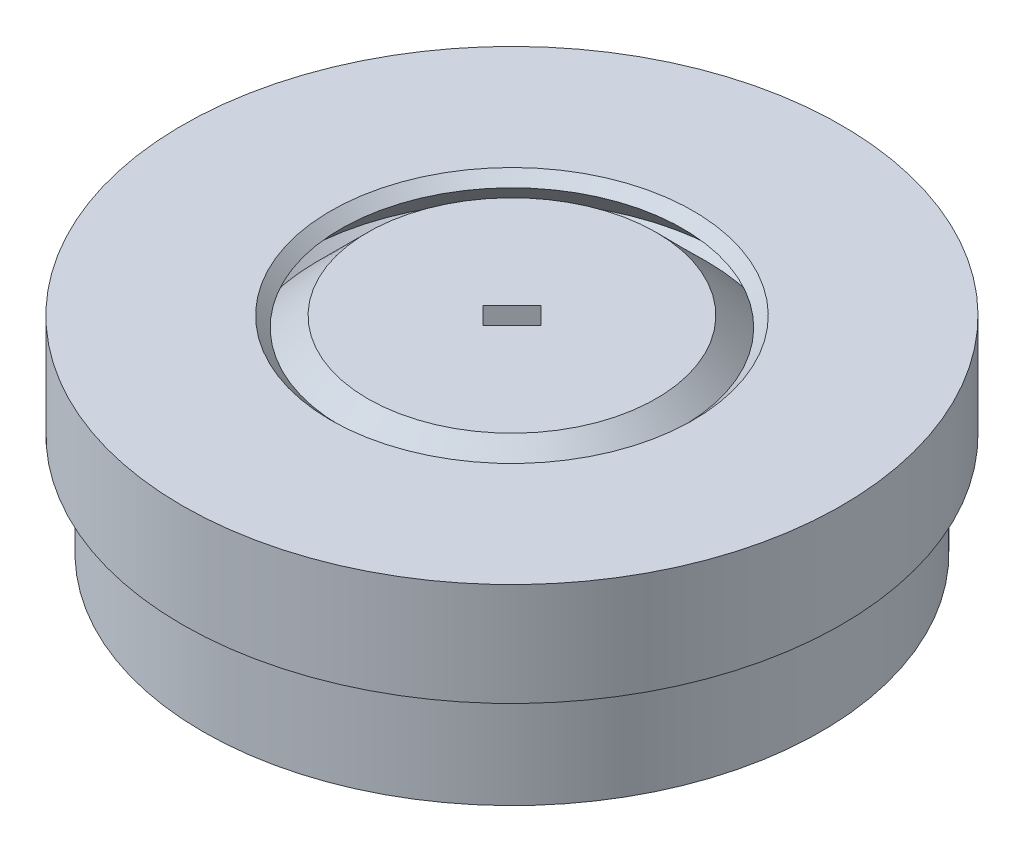
from build123d import *

# Parameters (mm, degrees)
SKETCH3_R             = 15
BOSS_EXTRUDE1_DEPTH   = 3
SKETCH3_W             = 6
SKETCH3_H             = 6
BOSS_EXTRUDE1_2_DEPTH = 3
FILLET2_R             = 0.5
FILLET3_R             = 0.5
CHAMFER1_SIZE         = 0.5
CHAMFER2_SIZE2        = 1
CHAMFER2_SIZE         = 0.707106781
CUT_EXTRUDE1_DEPTH    = 11


with BuildPart() as part:
    # Sketch3 → Boss-Extrude1 (new body)
    with BuildSketch(Plane(origin=(0, 0, 0), x_dir=(1, 0, 0), z_dir=(0, 1, 0))):
        Circle(SKETCH3_R)
        with BuildLine():
            Line((-6.465637778, 8.899186942), (-8.228993539, 11.326237918))
            add(Edge.make_bspline(
                [(-10.46162169, 3.399186936), (-10.467498345, 3.460626477), (-10.477851775, 3.583431102), (-10.49919448, 3.871841398), (-10.505566665, 4.111339029), (-10.51203319, 4.43658025), (-10.505633282, 4.710998163), (-10.494231342, 5.01562391), (-10.473247, 5.301518728), (-10.445591503, 5.597767263), (-10.409651581, 5.886588485), (-10.366577361, 6.178309212), (-10.315801087, 6.466538299), (-10.257886015, 6.75463807), (-10.181805067, 7.087772467), (-10.077371634, 7.489639712), (-9.935986845, 7.957756211), (-9.774040171, 8.418216115), (-9.610755449, 8.828116384), (-9.465500874, 9.16328093), (-9.340653869, 9.431941085), (-9.182264379, 9.756556112), (-9.004447659, 10.089396058), (-8.832785623, 10.394326968), (-8.62773532, 10.727607145), (-8.494256055, 10.939512615), (-8.335537891, 11.173163989), (-8.264543014, 11.275783985), (-8.228993539, 11.326237918)],
                knots=[0.074515508, 0.074515508, 0.074515508, 0.074515508, 0.074515508, 0.103872078, 0.133228686, 0.162585325, 0.191941925, 0.221298528, 0.250655154, 0.280011777, 0.309368359, 0.338724992, 0.36808162, 0.397438205, 0.426794822, 0.456151457, 0.50487246, 0.563585682, 0.622298905, 0.65165552, 0.681012134, 0.710368753, 0.739725372, 0.798438577, 0.827795195, 0.857151813, 0.88650843, 0.915865048, 0.915865048, 0.915865048, 0.915865048, 0.915865048], degree=4))
            Line((-10.46162169, 3.399186936), (-13.314791238, 4.326237912))
            add(Edge.make_bspline(
                [(-10.461621694, -3.39918695), (-10.502489264, -3.352935528), (-10.583048112, -3.259670093), (-10.769838042, -3.038886189), (-10.915766423, -2.848874013), (-11.112169944, -2.589549265), (-11.268291112, -2.363778739), (-11.438121271, -2.11062944), (-11.589189339, -1.867001387), (-11.740946092, -1.611075794), (-11.881634939, -1.356289562), (-12.018256304, -1.094964144), (-12.146594242, -0.83193637), (-12.269080761, -0.564817134), (-12.403341467, -0.250586485), (-12.555064685, 0.135915377), (-12.715833963, 0.597733473), (-12.855467892, 1.065443228), (-12.96430111, 1.493035863), (-13.043792467, 1.849568174), (-13.100703596, 2.140302033), (-13.163367732, 2.496020113), (-13.215149395, 2.869811331), (-13.255505783, 3.217406033), (-13.285513776, 3.607560904), (-13.302081692, 3.857453174), (-13.311012832, 4.139773302), (-13.313895291, 4.264524364), (-13.314791238, 4.326237912)],
                knots=[0.074515508, 0.074515508, 0.074515508, 0.074515508, 0.074515508, 0.103872078, 0.133228686, 0.162585325, 0.191941925, 0.221298528, 0.250655154, 0.280011777, 0.309368359, 0.338724992, 0.36808162, 0.397438205, 0.426794822, 0.456151457, 0.50487246, 0.563585682, 0.622298905, 0.65165552, 0.681012134, 0.710368753, 0.739725372, 0.798438577, 0.827795195, 0.857151813, 0.88650843, 0.915865048, 0.915865048, 0.915865048, 0.915865048, 0.915865048], degree=4))
            Line((-10.461621694, -3.39918695), (-13.314791238, -4.326237939))
            add(Edge.make_bspline(
                [(-6.465637787, -8.89918696), (-6.525886249, -8.885790128), (-6.645879774, -8.857688109), (-6.926769524, -8.788862545), (-7.156514419, -8.720914015), (-7.467835468, -8.626558981), (-7.726844732, -8.535672509), (-8.013037641, -8.430694086), (-8.278455252, -8.322390434), (-8.551658334, -8.204542661), (-8.815237591, -8.081111099), (-9.079369824, -7.949998419), (-9.337801244, -7.812639627), (-9.593903667, -7.668531394), (-9.887223, -7.493229922), (-10.237149757, -7.269724018), (-10.638664701, -6.990603139), (-11.026543818, -6.694292764), (-11.365924386, -6.412333616), (-11.639798679, -6.170616765), (-11.856729824, -5.968859654), (-12.116512017, -5.717910738), (-12.378113228, -5.445943787), (-12.615073271, -5.188454656), (-12.868677527, -4.890450991), (-13.028964243, -4.698022275), (-13.202133295, -4.474870085), (-13.277792088, -4.375638622), (-13.314791238, -4.326237939)],
                knots=[0.074515508, 0.074515508, 0.074515508, 0.074515508, 0.074515508, 0.103872078, 0.133228686, 0.162585325, 0.191941925, 0.221298528, 0.250655154, 0.280011777, 0.309368359, 0.338724992, 0.36808162, 0.397438205, 0.426794822, 0.456151457, 0.50487246, 0.563585682, 0.622298905, 0.65165552, 0.681012134, 0.710368753, 0.739725372, 0.798438577, 0.827795195, 0.857151813, 0.88650843, 0.915865048, 0.915865048, 0.915865048, 0.915865048, 0.915865048], degree=4))
            Line((-6.465637787, -8.89918696), (-8.228993536, -11.326237945))
            add(Edge.make_bspline(
                [(-3e-09, -11.000000028), (-0.056616494, -11.024574922), (-0.170211246, -11.072370334), (-0.437910479, -11.181792136), (-0.663717148, -11.261861282), (-0.971041664, -11.368516377), (-1.234006289, -11.447229502), (-1.527245984, -11.530520145), (-1.805632632, -11.598909207), (-2.095927751, -11.664153099), (-2.381719102, -11.719222868), (-2.672472667, -11.768403512), (-2.962285549, -11.809180092), (-3.254181455, -11.843127311), (-3.594521401, -11.873714219), (-4.008991568, -11.898575931), (-4.497887117, -11.90876696), (-4.985854784, -11.897036455), (-5.42615086, -11.868409605), (-5.789797417, -11.833835836), (-6.083888255, -11.798119832), (-6.441560536, -11.747794036), (-6.813058524, -11.681533485), (-7.156111539, -11.61250202), (-7.536443852, -11.520476832), (-7.779225291, -11.459012899), (-8.050487563, -11.3802652), (-8.170023602, -11.344456382), (-8.228993536, -11.326237945)],
                knots=[0.074515508, 0.074515508, 0.074515508, 0.074515508, 0.074515508, 0.103872078, 0.133228686, 0.162585325, 0.191941925, 0.221298528, 0.250655154, 0.280011777, 0.309368359, 0.338724992, 0.36808162, 0.397438205, 0.426794822, 0.456151457, 0.50487246, 0.563585682, 0.622298905, 0.65165552, 0.681012134, 0.710368753, 0.739725372, 0.798438577, 0.827795195, 0.857151813, 0.88650843, 0.915865048, 0.915865048, 0.915865048, 0.915865048, 0.915865048], degree=4))
            Line((-3e-09, -11.000000028), (3e-09, -14.000000025))
            add(Edge.make_bspline(
                [(6.465637782, -8.899186966), (6.434278839, -8.952346811), (6.370472193, -9.057783433), (6.218215485, -9.303657191), (6.082597516, -9.50116032), (5.896657051, -9.768086923), (5.730180615, -9.986333907), (5.54190173, -10.226079421), (5.356880283, -10.445038901), (5.160375996, -10.668453507), (4.961535134, -10.880989828), (4.755218216, -11.091678462), (4.544722542, -11.295015147), (4.328527467, -11.494051132), (4.071165201, -11.718843262), (3.75046514, -11.982576261), (3.360930468, -12.27818657), (2.959261316, -12.555516591), (2.586227868, -12.791156523), (2.271709671, -12.976931839), (2.012791845, -13.120899242), (1.693848131, -13.29041931), (1.35435297, -13.455174437), (1.036241574, -13.600968312), (0.674455221, -13.750072095), (0.441913317, -13.843050077), (0.176170794, -13.938785814), (0.058416211, -13.980077393), (3e-09, -14.000000025)],
                knots=[0.074515508, 0.074515508, 0.074515508, 0.074515508, 0.074515508, 0.103872078, 0.133228686, 0.162585325, 0.191941925, 0.221298528, 0.250655154, 0.280011777, 0.309368359, 0.338724992, 0.36808162, 0.397438205, 0.426794822, 0.456151457, 0.50487246, 0.563585682, 0.622298905, 0.65165552, 0.681012134, 0.710368753, 0.739725372, 0.798438577, 0.827795195, 0.857151813, 0.88650843, 0.915865048, 0.915865048, 0.915865048, 0.915865048, 0.915865048], degree=4))
            Line((6.465637782, -8.899186966), (8.228993543, -11.326237943))
            add(Edge.make_bspline(
                [(10.461621695, -3.39918696), (10.46749835, -3.460626502), (10.477851779, -3.583431127), (10.499194485, -3.871841423), (10.505566669, -4.111339053), (10.512033194, -4.436580274), (10.505633286, -4.710998187), (10.494231346, -5.015623935), (10.473247004, -5.301518753), (10.445591508, -5.597767288), (10.409651586, -5.886588509), (10.366577366, -6.178309237), (10.315801092, -6.466538323), (10.257886019, -6.754638095), (10.181805071, -7.087772492), (10.077371639, -7.489639737), (9.93598685, -7.957756236), (9.774040175, -8.41821614), (9.610755453, -8.828116408), (9.465500878, -9.163280954), (9.340653874, -9.43194111), (9.182264384, -9.756556137), (9.004447663, -10.089396083), (8.832785627, -10.394326993), (8.627735324, -10.72760717), (8.494256059, -10.93951264), (8.335537896, -11.173164014), (8.264543019, -11.27578401), (8.228993543, -11.326237943)],
                knots=[0.074515508, 0.074515508, 0.074515508, 0.074515508, 0.074515508, 0.103872078, 0.133228686, 0.162585325, 0.191941925, 0.221298528, 0.250655154, 0.280011777, 0.309368359, 0.338724992, 0.36808162, 0.397438205, 0.426794822, 0.456151457, 0.50487246, 0.563585682, 0.622298905, 0.65165552, 0.681012134, 0.710368753, 0.739725372, 0.798438577, 0.827795195, 0.857151813, 0.88650843, 0.915865048, 0.915865048, 0.915865048, 0.915865048, 0.915865048], degree=4))
            Line((10.461621695, -3.39918696), (13.314791243, -4.326237936))
            add(Edge.make_bspline(
                [(10.461621698, 3.399186925), (10.502489268, 3.352935503), (10.583048116, 3.259670068), (10.769838046, 3.038886165), (10.915766427, 2.848873988), (11.112169948, 2.589549241), (11.268291116, 2.363778714), (11.438121275, 2.110629415), (11.589189343, 1.867001362), (11.740946097, 1.611075769), (11.881634944, 1.356289537), (12.018256309, 1.09496412), (12.146594247, 0.831936345), (12.269080766, 0.564817109), (12.403341472, 0.25058646), (12.55506469, -0.135915401), (12.715833967, -0.597733498), (12.855467896, -1.065443253), (12.964301114, -1.493035888), (13.043792471, -1.849568198), (13.1007036, -2.140302058), (13.163367737, -2.496020137), (13.2151494, -2.869811356), (13.255505787, -3.217406058), (13.285513781, -3.607560929), (13.302081696, -3.857453198), (13.311012837, -4.139773327), (13.313895295, -4.264524389), (13.314791243, -4.326237936)],
                knots=[0.074515508, 0.074515508, 0.074515508, 0.074515508, 0.074515508, 0.103872078, 0.133228686, 0.162585325, 0.191941925, 0.221298528, 0.250655154, 0.280011777, 0.309368359, 0.338724992, 0.36808162, 0.397438205, 0.426794822, 0.456151457, 0.50487246, 0.563585682, 0.622298905, 0.65165552, 0.681012134, 0.710368753, 0.739725372, 0.798438577, 0.827795195, 0.857151813, 0.88650843, 0.915865048, 0.915865048, 0.915865048, 0.915865048, 0.915865048], degree=4))
            Line((10.461621698, 3.399186925), (13.314791242, 4.326237914))
            add(Edge.make_bspline(
                [(6.465637791, 8.899186935), (6.525886254, 8.885790104), (6.645879778, 8.857688084), (6.926769528, 8.788862521), (7.156514423, 8.720913991), (7.467835472, 8.626558956), (7.726844736, 8.535672484), (8.013037645, 8.430694062), (8.278455256, 8.322390409), (8.551658338, 8.204542637), (8.815237596, 8.081111074), (9.079369828, 7.949998394), (9.337801248, 7.812639602), (9.593903671, 7.668531369), (9.887223005, 7.493229897), (10.237149761, 7.269723993), (10.638664705, 6.990603115), (11.026543823, 6.694292739), (11.36592439, 6.412333591), (11.639798684, 6.17061674), (11.856729829, 5.968859629), (12.116512021, 5.717910713), (12.378113233, 5.445943763), (12.615073276, 5.188454631), (12.868677531, 4.890450966), (13.028964248, 4.69802225), (13.202133299, 4.474870061), (13.277792092, 4.375638597), (13.314791242, 4.326237914)],
                knots=[0.074515508, 0.074515508, 0.074515508, 0.074515508, 0.074515508, 0.103872078, 0.133228686, 0.162585325, 0.191941925, 0.221298528, 0.250655154, 0.280011777, 0.309368359, 0.338724992, 0.36808162, 0.397438205, 0.426794822, 0.456151457, 0.50487246, 0.563585682, 0.622298905, 0.65165552, 0.681012134, 0.710368753, 0.739725372, 0.798438577, 0.827795195, 0.857151813, 0.88650843, 0.915865048, 0.915865048, 0.915865048, 0.915865048, 0.915865048], degree=4))
            Line((6.465637791, 8.899186935), (8.228993532, 11.326237921))
            add(Edge.make_bspline(
                [(8e-09, 11.000000003), (0.056616489, 11.024574893), (0.170211242, 11.072370306), (0.437910475, 11.181792108), (0.663717143, 11.261861254), (0.97104166, 11.368516349), (1.234006284, 11.447229474), (1.52724598, 11.530520118), (1.805632628, 11.59890918), (2.095927746, 11.664153072), (2.381719097, 11.719222841), (2.672472662, 11.768403485), (2.962285544, 11.809180066), (3.254181451, 11.843127284), (3.594521396, 11.873714193), (4.008991563, 11.898575905), (4.497887113, 11.908766934), (4.985854779, 11.89703643), (5.426150855, 11.86840958), (5.789797413, 11.833835811), (6.08388825, 11.798119807), (6.441560531, 11.747794011), (6.813058519, 11.681533461), (7.156111535, 11.612501996), (7.536443848, 11.520476808), (7.779225286, 11.459012875), (8.050487558, 11.380265176), (8.170023598, 11.344456359), (8.228993532, 11.326237921)],
                knots=[0.074515509, 0.074515509, 0.074515509, 0.074515509, 0.074515509, 0.103872078, 0.133228686, 0.162585325, 0.191941925, 0.221298528, 0.250655154, 0.280011777, 0.309368359, 0.338724992, 0.36808162, 0.397438205, 0.426794822, 0.456151457, 0.50487246, 0.563585682, 0.622298905, 0.65165552, 0.681012134, 0.710368753, 0.739725372, 0.798438577, 0.827795195, 0.857151813, 0.88650843, 0.915865049, 0.915865049, 0.915865049, 0.915865049, 0.915865049], degree=4))
            Line((8e-09, 11.000000003), (1e-09, 14))
            add(Edge.make_bspline(
                [(-6.465637778, 8.899186942), (-6.434278835, 8.952346786), (-6.370472188, 9.057783408), (-6.218215481, 9.303657166), (-6.082597512, 9.501160295), (-5.896657047, 9.768086898), (-5.730180611, 9.986333882), (-5.541901726, 10.226079396), (-5.356880278, 10.445038876), (-5.160375992, 10.668453483), (-4.961535129, 10.880989803), (-4.755218212, 11.091678438), (-4.544722537, 11.295015122), (-4.328527463, 11.494051107), (-4.071165197, 11.718843237), (-3.750465135, 11.982576236), (-3.360930464, 12.278186545), (-2.959261311, 12.555516566), (-2.586227863, 12.791156498), (-2.271709666, 12.976931814), (-2.012791841, 13.120899218), (-1.693848126, 13.290419285), (-1.354352966, 13.455174412), (-1.03624157, 13.600968287), (-0.674455217, 13.75007207), (-0.441913313, 13.843050053), (-0.176170789, 13.938785789), (-0.058416207, 13.980077368), (1e-09, 14)],
                knots=[0.074515508, 0.074515508, 0.074515508, 0.074515508, 0.074515508, 0.103872078, 0.133228686, 0.162585325, 0.191941925, 0.221298528, 0.250655154, 0.280011777, 0.309368359, 0.338724992, 0.36808162, 0.397438205, 0.426794822, 0.456151457, 0.50487246, 0.563585682, 0.622298905, 0.65165552, 0.681012134, 0.710368753, 0.739725372, 0.798438577, 0.827795195, 0.857151813, 0.88650843, 0.915865048, 0.915865048, 0.915865048, 0.915865048, 0.915865048], degree=4))
        make_face(mode=Mode.SUBTRACT)
    extrude(amount=BOSS_EXTRUDE1_DEPTH)



with BuildPart() as body_2:
    # Sketch3 → Boss-Extrude1 2 (new body)
    with BuildSketch(Plane(origin=(0, 0, 0), x_dir=(1, 0, 0), z_dir=(0, 1, 0))):
        Rectangle(SKETCH3_W, SKETCH3_H)
    extrude(amount=BOSS_EXTRUDE1_2_DEPTH)


with BuildPart() as part_1:
    add(part.part)

    add(body_2.part)  # Revolve1 merges body 2
    # Sketch5 → Revolve1 (revolve)
    with BuildSketch(Plane(origin=(0, 0, 0), x_dir=(0, 0, -1), z_dir=(1, 0, 0))):
        Polygon((-7, 10), (-9.5, 7.5), (-7, 5), (-7, 3), (0, 3), (0, 10), align=None)
        Polygon((-7.8, 10), (-10.3, 7.5), (-7.8, 5), (-10.3, 5), (-10.3, 3), (-15, 3), (-15, 5), (-16, 5), (-16, 10), align=None)
    revolve(axis=Axis((0, 10, 0), (0, -1, 0)))

    # Fillet2
    fillet2_edges = [part_1.edges().sort_by_distance(p)[0] for p in [
        (0, 3, -10.3),
    ]]
    fillet(fillet2_edges, radius=FILLET2_R)

    # Fillet3
    fillet3_edges = [part_1.edges().sort_by_distance(p)[0] for p in [
        (0, 3, -7),
    ]]
    fillet(fillet3_edges, radius=FILLET3_R)

    # Chamfer1
    chamfer1_edges = [part_1.edges().sort_by_distance(p)[0] for p in [
        (0, 0, 3),
        (-3, 0, 0),
        (0, 0, -3),
        (3, 0, 0),
    ]]
    chamfer(chamfer1_edges, length=CHAMFER1_SIZE)

    # Chamfer2
    chamfer2_edges = [part_1.edges().sort_by_distance(p)[0] for p in [
        (0, 10, -7.8),
    ]]
    chamfer(chamfer2_edges, length=CHAMFER2_SIZE, length2=CHAMFER2_SIZE2)

    # Sketch6 → Cut-Extrude1 (cut, through all)
    with BuildSketch(Plane.XZ):
        Polygon((-0.282842712, 1.13137085), (1.13137085, -0.282842712), (0.282842712, -1.13137085), (-1.13137085, 0.282842712), align=None)
    extrude(amount=-CUT_EXTRUDE1_DEPTH, mode=Mode.SUBTRACT)


solid = part_1.part
